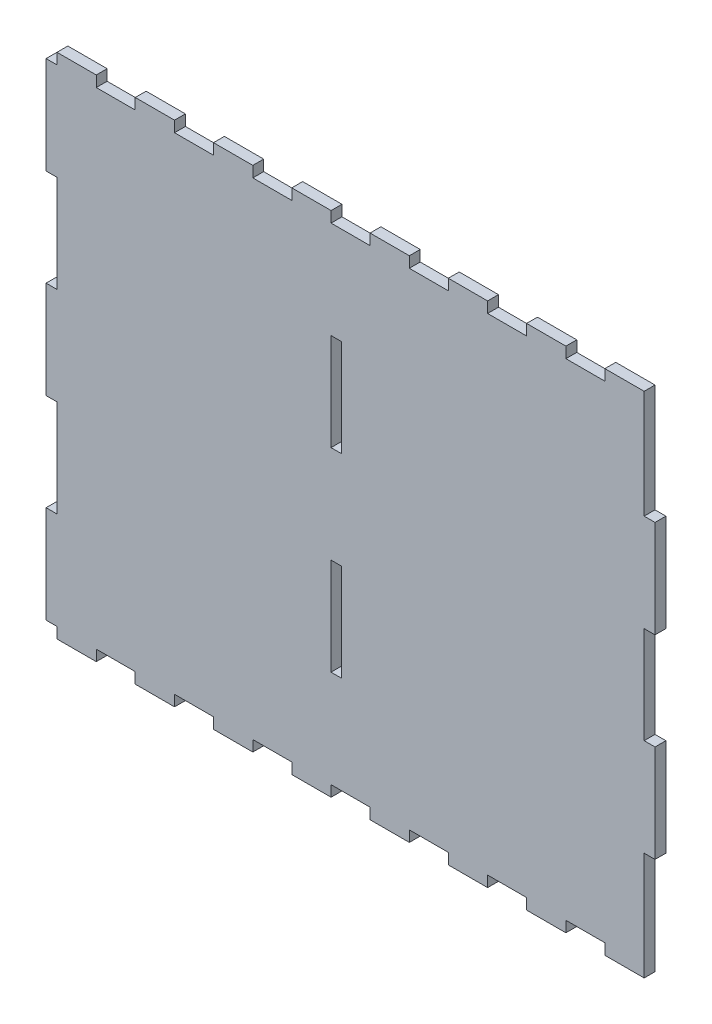
from build123d import *

# Parameters (mm, degrees)
SKETCH1_W           = 5.4
SKETCH1_H           = 48.265
BOSS_EXTRUDE1_DEPTH = 5.4
SKETCH2_W           = 5.31872
SKETCH2_H           = 48.18372
BOSS_EXTRUDE2_DEPTH = 5.4


with BuildPart() as part:
    # Sketch1 → Boss-Extrude1 (new body)
    with BuildSketch(Plane.XY):
        Polygon((-181.028382108, -13.967555325), (-181.028382108, -8.567555325), (-200.453382108, -8.567555325), (-200.453382108, -13.967555325), (-219.878382108, -13.967555325), (-219.878382108, -8.567555325), (-239.303382108, -8.567555325), (-239.303382108, -13.967555325), (-244.703382108, -13.967555325), (-244.703382108, -62.232555325), (-239.303382108, -62.232555325), (-239.303382108, -110.497555325), (-244.703382108, -110.497555325), (-244.703382108, -158.762555325), (-239.303382108, -158.762555325), (-239.303382108, -207.027555325), (-244.703382109, -207.027555325), (-244.703382109, -255.292555325), (-239.303382108, -255.292555325), (-239.303382108, -260.692555325), (-219.878382108, -260.692555325), (-219.878382108, -255.292555325), (-200.453382108, -255.292555325), (-200.453382108, -260.692555325), (-181.028382108, -260.692555325), (-181.028382108, -255.292555325), (-161.603382108, -255.292555325), (-161.603382108, -260.692555325), (-142.178382108, -260.692555325), (-142.178382108, -255.292555325), (-122.753382108, -255.292555325), (-122.753382108, -260.692555325), (-103.328382108, -260.692555325), (-103.328382108, -255.292555325), (-83.903382108, -255.292555325), (-83.903382108, -260.692555325), (-64.478382108, -260.692555325), (-64.478382108, -255.292555325), (-45.053382108, -255.292555325), (-45.053382108, -260.692555325), (-25.628382108, -260.692555325), (-25.628382108, -255.292555325), (-6.203382108, -255.292555325), (-6.203382108, -260.692555325), (13.221617892, -260.692555325), (13.221617892, -255.292555325), (32.646617892, -255.292555325), (32.646617892, -260.692555325), (52.071617892, -260.692555325), (52.071617892, -207.027555325), (57.471617892, -207.027555325), (57.471617892, -158.762555325), (52.071617892, -158.762555325), (52.071617892, -110.497555325), (57.471617892, -110.497555325), (57.471617892, -62.232555325), (52.071617892, -62.232555325), (52.071617892, -8.567555325), (32.646617892, -8.567555325), (32.646617892, -13.967555325), (13.221617892, -13.967555325), (13.221617892, -8.567555325), (-6.203382108, -8.567555325), (-6.203382108, -13.967555325), (-25.628382108, -13.967555325), (-25.628382108, -8.567555325), (-45.053382108, -8.567555325), (-45.053382108, -13.967555325), (-64.478382108, -13.967555325), (-64.478382108, -8.567555325), (-83.903382108, -8.567555325), (-83.903382108, -13.967555325), (-103.328382108, -13.967555325), (-103.328382108, -8.567555325), (-122.753382108, -8.567555325), (-122.753382108, -13.967555325), (-142.178382108, -13.967555325), (-142.178382108, -8.567555325), (-161.603382108, -8.567555325), (-161.603382108, -13.967555325), align=None)
        with Locations((-100.653382108, -182.895055325)):
            Rectangle(SKETCH1_W, SKETCH1_H, mode=Mode.SUBTRACT)
        with Locations((-100.653382108, -86.365055325)):
            Rectangle(SKETCH1_W, SKETCH1_H, mode=Mode.SUBTRACT)
    extrude(amount=BOSS_EXTRUDE1_DEPTH)

    # Sketch2 → Boss-Extrude2 (add)
    with BuildSketch(Plane.XY.offset(5.4)):
        Polygon((-239.344022108, -8.526915325), (-239.344022108, -13.926915325), (-244.744022108, -13.926915325), (-244.744022108, -62.273195325), (-239.344022108, -62.273195325), (-239.344022108, -110.456915325), (-244.744022108, -110.456915325), (-244.744022108, -158.803195325), (-239.344022108, -158.803195325), (-239.344022108, -206.986915325), (-244.744022109, -206.986915325), (-244.744022109, -255.333195325), (-239.344022108, -255.333195325), (-239.344022108, -260.733195325), (-219.837742108, -260.733195325), (-219.837742108, -255.333195325), (-200.494022108, -255.333195325), (-200.494022108, -260.733195325), (-180.987742108, -260.733195325), (-180.987742108, -255.333195325), (-161.644022108, -255.333195325), (-161.644022108, -260.733195325), (-142.137742108, -260.733195325), (-142.137742108, -255.333195325), (-122.794022108, -255.333195325), (-122.794022108, -260.733195325), (-103.287742108, -260.733195325), (-103.287742108, -255.333195325), (-83.944022108, -255.333195325), (-83.944022108, -260.733195325), (-64.437742108, -260.733195325), (-64.437742108, -255.333195325), (-45.094022108, -255.333195325), (-45.094022108, -260.733195325), (-25.587742108, -260.733195325), (-25.587742108, -255.333195325), (-6.244022108, -255.333195325), (-6.244022108, -260.733195325), (13.262257892, -260.733195325), (13.262257892, -255.333195325), (32.605977892, -255.333195325), (32.605977892, -260.733195325), (52.112257892, -260.733195325), (52.112257892, -207.068195325), (57.512257892, -207.068195325), (57.512257892, -158.721915325), (52.112257892, -158.721915325), (52.112257892, -110.538195325), (57.512257892, -110.538195325), (57.512257892, -62.191915325), (52.112257892, -62.191915325), (52.112257892, -8.526915325), (32.605977892, -8.526915325), (32.605977892, -13.926915325), (13.262257892, -13.926915325), (13.262257892, -8.526915325), (-6.244022108, -8.526915325), (-6.244022108, -13.926915325), (-25.587742108, -13.926915325), (-25.587742108, -8.526915325), (-45.094022108, -8.526915325), (-45.094022108, -13.926915325), (-64.437742108, -13.926915325), (-64.437742108, -8.526915325), (-83.944022108, -8.526915325), (-83.944022108, -13.926915325), (-103.287742108, -13.926915325), (-103.287742108, -8.526915325), (-122.794022108, -8.526915325), (-122.794022108, -13.926915325), (-142.137742108, -13.926915325), (-142.137742108, -8.526915325), (-161.644022108, -8.526915325), (-161.644022108, -13.926915325), (-180.987742108, -13.926915325), (-180.987742108, -8.526915325), (-200.494022108, -8.526915325), (-200.494022108, -13.926915325), (-219.837742108, -13.926915325), (-219.837742108, -8.526915325), align=None)
        with Locations((-100.653382108, -86.365055325)):
            Rectangle(SKETCH2_W, SKETCH2_H, mode=Mode.SUBTRACT)
        with Locations((-100.653382108, -182.895055325)):
            Rectangle(SKETCH2_W, SKETCH2_H, mode=Mode.SUBTRACT)
    extrude(amount=-BOSS_EXTRUDE2_DEPTH)


solid = part.part
